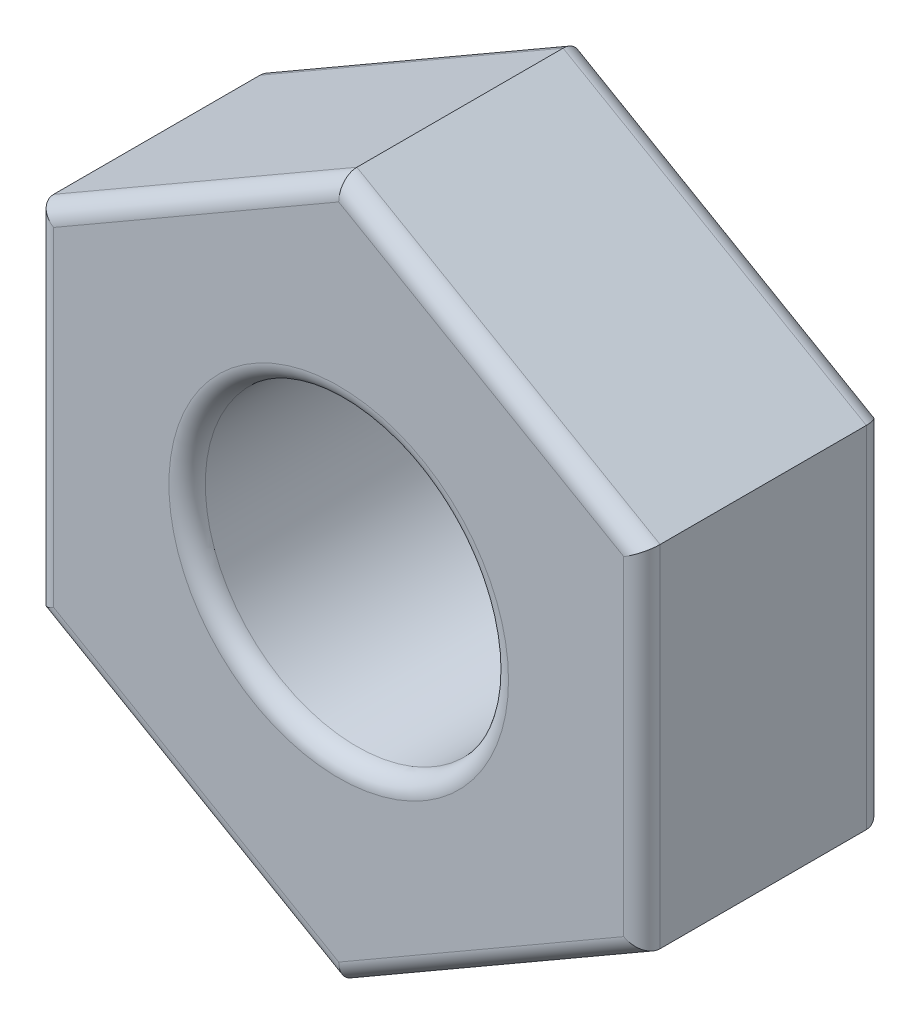
from build123d import *

# Parameters (mm, degrees)
SKETCH1_R           = 1.25
BOSS_EXTRUDE1_DEPTH = 2
FILLET1_R           = 0.15


with BuildPart() as part:
    # Sketch1 → Boss-Extrude1 (new body)
    with BuildSketch(Plane.XY):
        Polygon((0, 2.886751346), (-2.5, 1.443375673), (-2.5, -1.443375673), (0, -2.886751346), (2.5, -1.443375673), (2.5, 1.443375673), align=None)
        Circle(SKETCH1_R, mode=Mode.SUBTRACT)
    extrude(amount=BOSS_EXTRUDE1_DEPTH)

    # Fillet1
    fillet1_edges = [part.edges().sort_by_distance(p)[0] for p in [
        (-2.5, 0, 2),
        (-1.25, -2.165063509, 2),
        (-1.25, 0, 0),
        (-1.25, 0, 2),
        (1.25, -2.165063509, 2),
        (2.5, 0, 2),
        (1.25, 2.165063509, 2),
        (2.5, 0, 0),
        (1.25, -2.165063509, 0),
        (-1.25, -2.165063509, 0),
        (-2.5, 0, 0),
        (-1.25, 2.165063509, 0),
        (1.25, 2.165063509, 0),
        (-1.25, 2.165063509, 2),
    ]]
    fillet(fillet1_edges, radius=FILLET1_R)


solid = part.part
